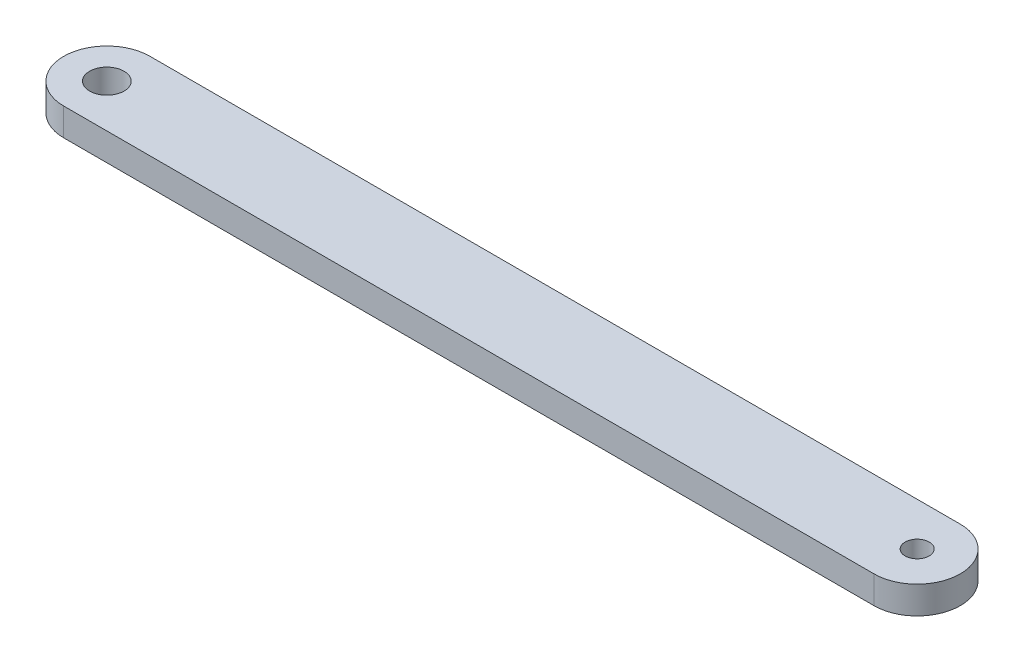
from build123d import *

# Parameters (mm, degrees)
SKETCH_1_R      = 1
SKETCH_1_R_2    = 0.7
EXTRUDE_1_DEPTH = 1.6


with BuildPart() as part:
    # 草图1 → 凸台-拉伸1 (new body)
    with BuildSketch(Plane(origin=(0, 0, 0), x_dir=(1, 0, 0), z_dir=(0, 1, 0))):
        with BuildLine():
            Line((0, 2.5), (47, 2.5))
            ThreePointArc((47, 2.5), (49.5, 0), (47, -2.5))
            Line((47, -2.5), (0, -2.5))
            ThreePointArc((0, -2.5), (-2.5, 0), (0, 2.5))
        make_face()
        Circle(SKETCH_1_R, mode=Mode.SUBTRACT)
        with Locations((47, 0)):
            Circle(SKETCH_1_R_2, mode=Mode.SUBTRACT)
    extrude(amount=EXTRUDE_1_DEPTH)


solid = part.part
